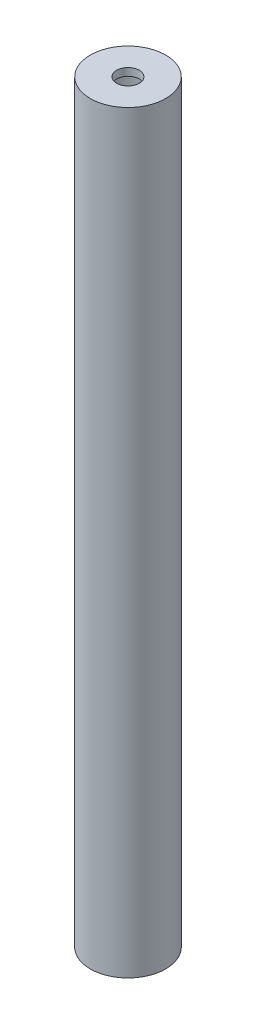
from build123d import *

# Parameters (mm, degrees)
SKETCH1_R               = 10
BOSS_EXTRUDE1_DEPTH     = 200
SHELL1_T                = 2
SKETCH2_R               = 3
CUT_EXTRUDE1_DEPTH      = 1
CUT_EXTRUDE1_DEPTH_BACK = 201


with BuildPart() as part:
    # Sketch1 → Boss-Extrude1 (new body)
    with BuildSketch(Plane(origin=(0, 0, 0), x_dir=(1, 0, 0), z_dir=(0, 1, 0))):
        Circle(SKETCH1_R)
    extrude(amount=BOSS_EXTRUDE1_DEPTH)

    # Shell1 (no face opened: a closed hollow body)
    add(offset(amount=-SHELL1_T, mode=Mode.PRIVATE), mode=Mode.SUBTRACT)

    # Sketch2 → Cut-Extrude1 (cut, two sides)
    with BuildSketch(Plane(origin=(0, 200, 0), x_dir=(1, 0, 0), z_dir=(0, 1, 0))) as cut_extrude1_sk:
        Circle(SKETCH2_R)
    extrude(amount=CUT_EXTRUDE1_DEPTH, mode=Mode.SUBTRACT)
    extrude(cut_extrude1_sk.sketch, amount=-CUT_EXTRUDE1_DEPTH_BACK, mode=Mode.SUBTRACT)


solid = part.part
